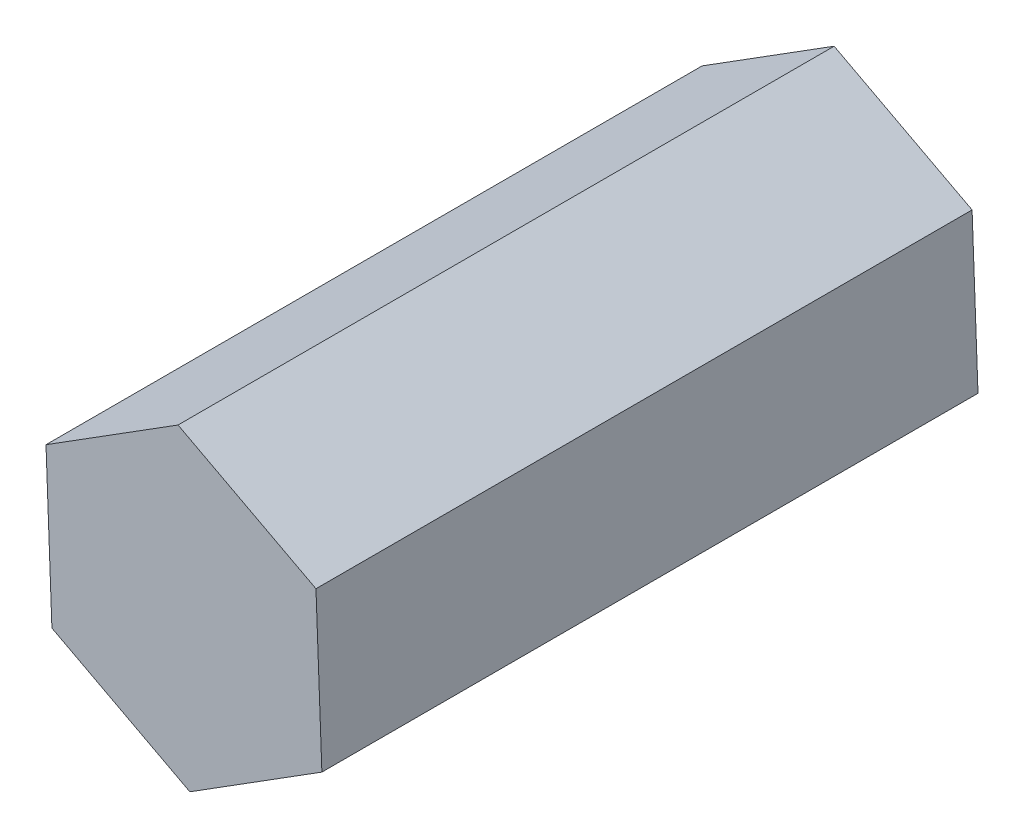
from build123d import *

# Parameters (mm, degrees)
BOSS_EXTRUDE1_DEPTH = 17
CUT_EXTRUDE7_DEPTH  = 8


with BuildPart() as part:
    # Sketch1 → Boss-Extrude1 (new body)
    with BuildSketch(Plane.XY):
        Polygon((3.574198426, -1.886382503), (3.420754381, 2.152155384), (-0.153444044, 4.038537886), (-3.574198426, 1.886382503), (-3.420754381, -2.152155384), (0.153444044, -4.038537886), align=None)
    extrude(amount=BOSS_EXTRUDE1_DEPTH)

    # Sketch2 → Cut-Extrude7 (cut)
    with BuildSketch(Plane.XY):
        with BuildLine():
            Line((0.76003439, 1.293192842), (1.195356952, -0.906157689))
            ThreePointArc((1.195356952, -0.906157689), (-1.471453198, -0.291248151), (0.76003439, 1.293192842))
        make_face()
    extrude(amount=CUT_EXTRUDE7_DEPTH, mode=Mode.SUBTRACT)


solid = part.part
